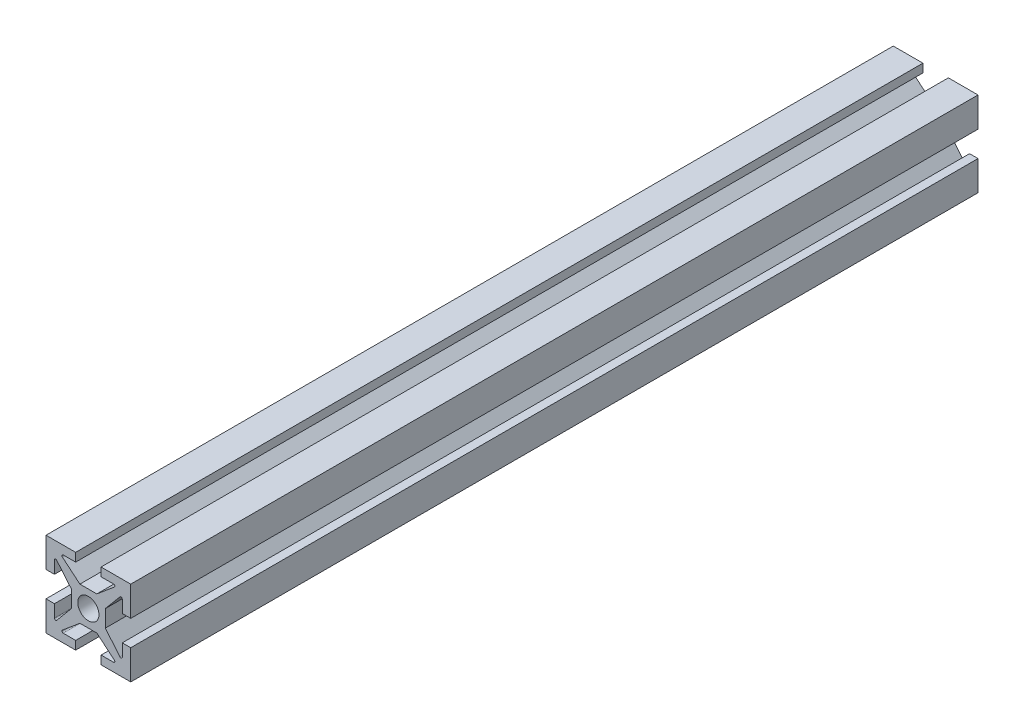
from build123d import *

# Parameters (mm, degrees)
BOSS_EXTRU_1_DEPTH           = 100
R_P_TITION_CIRCULAIRE1_COUNT = 4


with BuildPart() as part:
    # Esquisse1 → Boss.-Extru.1 (new body)
    with BuildSketch(Plane.XY):
        with BuildLine():
            Line((0, 2), (0, 1.25))
            ThreePointArc((0, 1.25), (-0.883883476, 0.883883476), (-1.25, 0))
            Line((-1.25, 0), (-2, 0))
            Line((-2, 0), (-2, 1))
            Line((-2, 1), (-3.735093334, 3.067803714))
            ThreePointArc((-3.735093334, 3.067803714), (-3.901303021, 3.112339465), (-4, 2.971385572))
            Line((-4, 2.971385572), (-4, 1.5))
            Line((-4, 1.5), (-5, 1.5))
            Line((-5, 1.5), (-5, 5))
            Line((-5, 5), (-1.5, 5))
            Line((-1.5, 5), (-1.5, 4))
            Line((-1.5, 4), (-2.971385572, 4))
            ThreePointArc((-2.971385572, 4), (-3.112339465, 3.901303021), (-3.067803714, 3.735093334))
            Line((-3.067803714, 3.735093334), (-1, 2))
            Line((-1, 2), (0, 2))
        make_face()
    boss_extru_1 = extrude(amount=BOSS_EXTRU_1_DEPTH)

    # Répétition circulaire1: Boss.-Extru.1 ×4 about axis
    r_p_tition_circulaire1_axis = Axis((0, 0, 105), (0, 0, -1))
    for i in range(1, R_P_TITION_CIRCULAIRE1_COUNT):
        add(boss_extru_1.rotate(r_p_tition_circulaire1_axis, i * 360 / R_P_TITION_CIRCULAIRE1_COUNT))


solid = part.part
